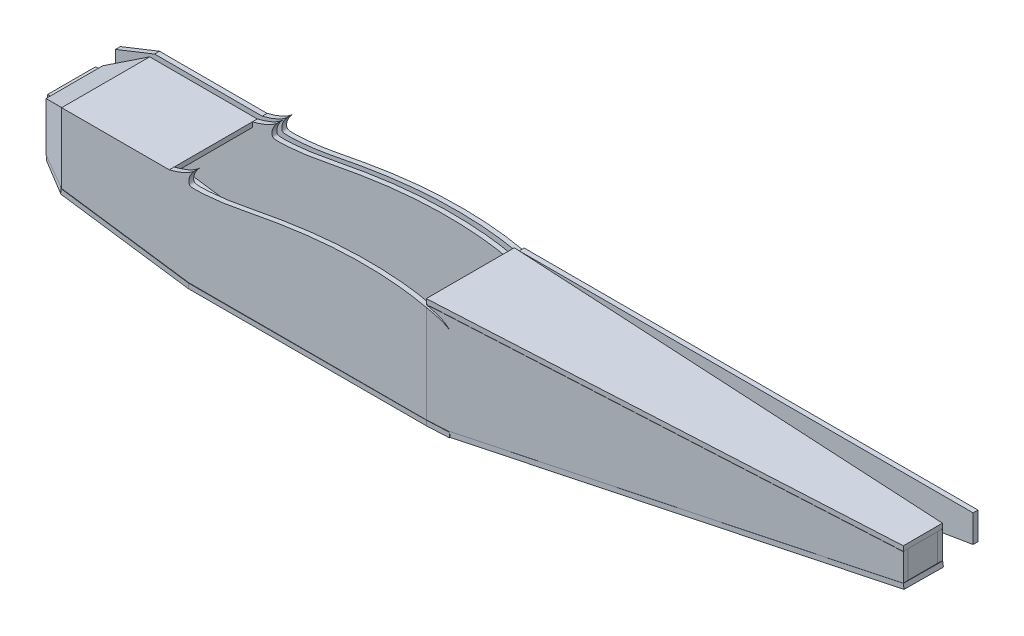
from build123d import *

# Parameters (mm, degrees)
BOSS_EXTRUDE1_DEPTH      = 5
BOSS_EXTRUDE5_DEPTH      = 5
BOSS_EXTRUDE7_DEPTH      = 5
BOSS_EXTRUDE8_DEPTH      = 0.002362017
BOSS_EXTRUDE8_DEPTH_BACK = 5
SKETCH29_W               = 49.059566024
SKETCH29_H               = 50
BOSS_EXTRUDE9_DEPTH      = 5
SKETCH30_W               = 30.063860272
SKETCH30_H               = 28.056676552
BOSS_EXTRUDE10_DEPTH     = 5
BOSS_EXTRUDE11_DEPTH     = 5
BOSS_EXTRUDE12_DEPTH     = 5
BOSS_EXTRUDE18_DEPTH     = 5
BOSS_EXTRUDE22_DEPTH     = 5
SKETCH38_W               = 131.749500249
SKETCH38_H               = 90.710541034
BOSS_EXTRUDE23_DEPTH     = 5
BOSS_EXTRUDE24_DEPTH     = 5
BOSS_EXTRUDE25_DEPTH     = 5
BOSS_EXTRUDE26_DEPTH     = 5


with BuildPart() as part:
    # Sketch2 → Boss-Extrude1 (new body)
    with BuildSketch(Plane.XY):
        with BuildLine():
            Line((706.745016675, 12.167167725), (242.745016675, 12.167167725))
            add(Edge.make_bspline(
                [(124.432769118, 12.787670712), (127.16227005, 13.092620358), (134.123597034, 13.82075776), (145.337160555, 14.772933919), (158.034195691, 15.535723016), (170.62317806, 15.955070434), (182.967539293, 16.008037018), (194.929558709, 15.691023935), (206.372264097, 15.011452524), (217.158058547, 13.978091085), (227.158530716, 12.630605082), (236.243477661, 11.008093479), (244.3063824, 9.1648962), (251.198649303, 7.192592998), (256.839258968, 5.087580751), (260.863688767, 3.161225049), (263.830793422, 1.380051863), (264.970627441, 0.690767223), (266.241142455, -0.171709465), (265.1271527, 0.658288782), (264.38761939, 1.383899074), (262.745556708, 2.899479064), (260.808306665, 4.511766368), (258.158315002, 6.13713136), (254.863030227, 7.712293785), (250.884845976, 9.356166566), (246.768501257, 10.850330318), (243.974418041, 11.774554958), (242.745016675, 12.167167725)],
                knots=[0.741308268, 0.741308268, 0.741308268, 0.741308268, 0.756094118, 0.778988554, 0.801889683, 0.824566598, 0.846792285, 0.868338291, 0.888978163, 0.908492011, 0.926658768, 0.943286193, 0.95816921, 0.971135822, 0.981955623, 0.990251791, 0.995852565, 0.999000406, 1, 1.000979678, 1.003648862, 1.007483499, 1.012095277, 1.017525591, 1.02405178, 1.031783051, 1.040677828, 1.047625399, 1.047625399, 1.047625399, 1.047625399], degree=3))
            add(Edge.make_bspline(
                [(-0.004631492, -0.177095853), (-3.2424e-05, -0.612159569), (0.085818354, -1.580724728), (0.522318686, -3.135725997), (2.379653438, -4.019341379), (4.8768644, -4.143309834), (8.293039686, -4.263460548), (12.589121207, -4.078204492), (17.716554755, -3.737760317), (23.618277347, -3.192442572), (30.233898006, -2.454604218), (37.531157228, -1.508412573), (45.506488949, -0.18596896), (54.198724376, 1.472353893), (63.651318834, 3.277138343), (73.818068814, 5.182731977), (84.635116432, 7.110039685), (96.023020904, 8.98673187), (107.893434076, 10.750140868), (117.420174926, 11.983062096), (122.977811963, 12.625117673), (124.432769118, 12.787670712)],
                knots=[0.511222834, 0.511222834, 0.511222834, 0.511222834, 0.513579311, 0.516446927, 0.519350053, 0.523823355, 0.529973794, 0.537715654, 0.546967844, 0.557637367, 0.569620481, 0.582804124, 0.597246961, 0.613135037, 0.6304436, 0.649056124, 0.668822257, 0.689594964, 0.711189651, 0.733426689, 0.741308268, 0.741308268, 0.741308268, 0.741308268], degree=3))
            add(Edge.make_bspline(
                [(-0.004631492, 0), (-0.005251256, -0.059005577), (-0.005255839, -0.118033803), (-0.004631492, -0.177095853)],
                knots=[0.510902931, 0.510902931, 0.510902931, 0.510902931, 0.511222834, 0.511222834, 0.511222834, 0.511222834], degree=3))
            add(Edge.make_bspline(
                [(6.12052156, 12.167167725), (5.616532595, 11.641520131), (4.39592468, 10.276576859), (2.737558538, 7.984495431), (1.299070701, 5.365975303), (0.37715223, 2.879814503), (0.032445951, 1.079184417), (-0.00297281, 0.157917482), (-0.004631492, 0)],
                knots=[0.485956775, 0.485956775, 0.485956775, 0.485956775, 0.489874508, 0.49580325, 0.501149412, 0.505903073, 0.510046769, 0.510902931, 0.510902931, 0.510902931, 0.510902931], degree=3))
            add(Edge.make_bspline(
                [(-20, 0), (-11.467631005, 2.199778438), (-0.826940934, 5.513158107), (6.12052156, 12.167167725)],
                knots=[0, 0, 0, 0, 0.753912396, 0.753912396, 0.753912396, 0.753912396], degree=3))
            Line((-20, 0), (-130, 0))
            Line((-130, 0), (-170, -15.889508827))
            Line((-170, -15.889508827), (-170, -65.889508827))
            Line((-170, -65.889508827), (-0.004631492, -90))
            Line((-0.004631492, -90), (265.995368508, -90))
            Line((265.995368508, -90), (706.745016675, -15.889508827))
            Line((706.745016675, -15.889508827), (706.745016675, 12.167167725))
        make_face()
    extrude(amount=BOSS_EXTRUDE1_DEPTH)


with BuildPart() as body_2:
    # Sketch12 → Boss-Extrude5 (new body)
    with BuildSketch(Plane(origin=(6.087960166, 0, 112.775462826), x_dir=(0, -1, 0), z_dir=(0.05390453463598798, 0, 0.998546093651003))):
        with BuildLine():
            Line((-12.167167725, 700.327022144), (-12.167167725, 237.00163469))
            add(Edge.make_bspline(
                [(-12.167167725, 237.00163469), (-11.774554958, 238.229248622), (-10.850330318, 241.019269503), (-9.356166566, 245.129629442), (-7.712293785, 249.102029786), (-6.13713136, 252.392523525), (-4.511766368, 255.038662348), (-2.899479064, 256.973095811), (-1.383899074, 258.612771088), (-0.658288782, 259.351229186), (0.171709465, 260.463599304), (-0.690767223, 259.1949315), (-1.380051863, 258.056754693), (-3.161225049, 255.09396393), (-5.087580751, 251.075385275), (-7.192592998, 245.442976529), (-8.583779515, 240.588505828), (-9.330125423, 237.630121112), (-9.484391278, 237.001634689)],
                knots=[0.485956775, 0.485956775, 0.485956775, 0.485956775, 0.492904346, 0.501799123, 0.509530394, 0.516056583, 0.521486897, 0.526098675, 0.529933312, 0.532602496, 0.533582174, 0.534581768, 0.537729608, 0.543330383, 0.551626551, 0.562446352, 0.575412963, 0.578902473, 0.578902473, 0.578902473, 0.578902473], degree=3))
            Line((-9.484391278, 237.001634689), (90, 237.00163469))
            Line((90, 237.00163469), (90, 260.218182689))
            Line((90, 260.218182689), (15.889508827, 700.327022144))
            Line((15.889508827, 700.327022144), (-12.167167725, 700.327022144))
        make_face()
    extrude(amount=-BOSS_EXTRUDE5_DEPTH)


with BuildPart() as body_3:
    # Sketch24 → Boss-Extrude7 (new body)
    with BuildSketch(Plane(origin=(-65.985541798, 0, 132.000175045), x_dir=(0, -1, 0), z_dir=(-0.44713474135516806, 0, 0.8944666137275594))):
        Polygon((0, -71.567185649), (71.562720135, -71.567185649), (65.889508827, -107.345850198), (15.889508827, -107.345850198), align=None)
    extrude(amount=-BOSS_EXTRUDE7_DEPTH)


with BuildPart() as body_4:
    # Sketch7 → Boss-Extrude8 (new, two sides)
    with BuildSketch(Plane.XY.offset(100)) as boss_extrude8_sk:
        with BuildLine():
            Line((242.745016675, 8.972673423), (242.745016675, 9.484391278))
            add(Edge.make_bspline(
                [(242.745016673, 9.484391278), (240.689974326, 9.988080671), (235.605317426, 11.122064688), (227.158530716, 12.630605082), (217.158058547, 13.978091085), (206.372264097, 15.011452524), (194.929558709, 15.691023935), (182.967539293, 16.008037018), (170.62317806, 15.955070434), (158.034195691, 15.535723016), (145.337160555, 14.772933919), (132.664724075, 13.696880632), (120.144057274, 12.335578494), (107.893434076, 10.750140868), (96.023020904, 8.98673187), (84.635116432, 7.110039685), (73.818068814, 5.182731977), (63.651318834, 3.277138343), (54.198724376, 1.472353893), (45.506488949, -0.18596896), (37.531157228, -1.508412573), (30.233898006, -2.454604218), (23.618277347, -3.192442572), (17.716554755, -3.737760317), (12.589121207, -4.078204492), (8.293039686, -4.263460548), (4.8768644, -4.143309834), (2.379653438, -4.019341379), (0.522318686, -3.135725997), (0.022653703, -1.355705166), (-0.062141966, 0.585088837), (0.37715223, 2.879814503), (1.299070701, 5.365975303), (2.737558538, 7.984495431), (4.395924665, 10.276576839), (5.616532561, 11.641520093), (6.120521508, 12.16716767)],
                knots=[0.578902473, 0.578902473, 0.578902473, 0.578902473, 0.590295981, 0.606923406, 0.625090162, 0.644604011, 0.665243883, 0.686789889, 0.709015576, 0.731692491, 0.75459362, 0.777488056, 0.800155485, 0.822392523, 0.84398721, 0.864759917, 0.88452605, 0.903138573, 0.920447137, 0.936335213, 0.950778049, 0.963961693, 0.975944807, 0.986614329, 0.995866519, 1.00360838, 1.009758819, 1.014232121, 1.017135247, 1.020002863, 1.023535405, 1.0276791, 1.032432762, 1.037778924, 1.043707666, 1.047625399, 1.047625399, 1.047625399, 1.047625399], degree=3))
            add(Edge.make_bspline(
                [(6.120521505, 12.167167672), (-0.82694099, 5.51315809), (-11.467631027, 2.199778432), (-20, 0)],
                knots=[0, 0, 0, 0, 0.753912394, 0.753912394, 0.753912394, 0.753912394], degree=3))
            Line((-20, 0), (-130, 0))
            Line((-130, 0), (-130, -71.562720135))
            Line((-130, -71.562720135), (-0.004631492, -90))
            Line((-0.004631492, -90), (242.745016675, -90))
            Line((242.745016675, -90), (242.745016675, 8.972673423))
        make_face()
    extrude(amount=BOSS_EXTRUDE8_DEPTH)
    extrude(boss_extrude8_sk.sketch, amount=-BOSS_EXTRUDE8_DEPTH_BACK)


with BuildPart() as body_5:
    # Mirror8: mirrored copy
    add(body_4.part.mirror(Plane.XY.offset(55)))


with BuildPart() as body_6:
    # Mirror8 2: mirrored copy
    add(body_2.part.mirror(Plane.XY.offset(55)))


with BuildPart() as body_7:
    # Mirror8 3: mirrored copy
    add(body_3.part.mirror(Plane.XY.offset(55)))


with BuildPart() as body_8:
    # Sketch29 → Boss-Extrude9 (new body)
    with BuildSketch(Plane.ZY.offset(159.767147216)):
        with Locations((55, -40.889508827)):
            Rectangle(SKETCH29_W, SKETCH29_H)
    extrude(amount=BOSS_EXTRUDE9_DEPTH)


with BuildPart() as body_9:
    # Sketch30 → Boss-Extrude10 (new body)
    with BuildSketch(Plane.ZY.offset(-705.127249733)):
        with Locations((55, -1.861170551)):
            Rectangle(SKETCH30_W, SKETCH30_H)
    extrude(amount=BOSS_EXTRUDE10_DEPTH)


with BuildPart() as body_3_1:
    add(body_3.part)

    add(body_4.part)  # Boss-Extrude11 merges body 4

    add(body_5.part)  # Boss-Extrude11 merges body 5

    add(body_7.part)  # Boss-Extrude11 merges body 7
    # Sketch31 → Boss-Extrude11 (add)
    with BuildSketch(Plane(origin=(-25.709288265, 51.780691105, 0), x_dir=(-0.895676417082623, -0.4447063704086497, 0), z_dir=(0.4447063704086497, -0.895676417082623, 0))):
        Polygon((116.437934221, -9.997637983), (116.437934221, -99.818556509), (152.168272, -84.002116081), (152.168272, -25.997883919), align=None)
    extrude(amount=BOSS_EXTRUDE11_DEPTH)

    # Sketch32 → Boss-Extrude12 (add)
    with BuildSketch(Plane(origin=(0, 0, 0), x_dir=(1, 0, 0), z_dir=(0, 1, 0))):
        Polygon((-20, -9.997637983), (-130, -9.997637983), (-130, -100), (-20, -100.002362017), align=None)
    extrude(amount=-BOSS_EXTRUDE12_DEPTH)


with BuildPart() as body_7_2:
    # Sketch35 → Boss-Extrude18 (new body)
    with BuildSketch(Plane(origin=(0, 12.367167725, 0), x_dir=(1, 0, 0), z_dir=(0, 1, 0))):
        Polygon((242.745016675, -100.002362017), (242.745016675, -9.997637983), (705.396772407, -34.975339396), (705.396772407, -75.024660604), align=None)
    extrude(amount=BOSS_EXTRUDE18_DEPTH)


with BuildPart() as body_2_1:
    add(body_2.part)

    # Sketch37 → Boss-Extrude22 (add)
    with BuildSketch(Plane(origin=(22.083717843, -131.336207808, 1.192145802), x_dir=(-0.9861573751236441, -0.16580520617812686, 0.0015050227484399235), z_dir=(0.16581203662353491, -0.9861167514496837, 0.00895103463732636))):
        Polygon((-693.08030813, -34.769382943), (-693.08030813, -75.077651477), (-246.535889921, -97.979995355), (-246.535889921, -10.414101442), align=None)
    extrude(amount=BOSS_EXTRUDE22_DEPTH)



with BuildPart() as body_8_2:
    # Sketch38 → Boss-Extrude23 (new body)
    with BuildSketch(Plane(origin=(-12.54680907, -88.463541289, 0), x_dir=(-0.9900913282108018, 0.14042493297762504, 0), z_dir=(-0.14042493297762504, -0.9900913282108018, 0))):
        with Locations((52.898651704, -54.903356729)):
            Rectangle(SKETCH38_W, SKETCH38_H)
    extrude(amount=BOSS_EXTRUDE23_DEPTH)

    # Sketch45 → Boss-Extrude25 (add)
    with BuildSketch(Plane(origin=(0, -90.24, 0), x_dir=(-1, 0, 0), z_dir=(0, -1, 0))):
        Polygon((0.401411214, -100.258627246), (0.401411214, -9.548086212), (-242.745016675, -9.997637983), (-242.745016675, -100.002362017), align=None)
    extrude(amount=BOSS_EXTRUDE25_DEPTH)


with BuildPart() as body_9_2:
    # Sketch44 → Boss-Extrude24 (new body)
    with BuildSketch(Plane(origin=(-16.260399931, -91.72559224, 0), x_dir=(-0.9846481744002387, 0.1745507738461144, 0), z_dir=(-0.1745507738461144, -0.9846481744002387, 0))):
        Polygon((115.748144024, -10.115773796), (147.506135541, -25.860574924), (147.506135541, -83.361404055), (116.180199117, -99.791548904), align=None)
    extrude(amount=BOSS_EXTRUDE24_DEPTH)


with BuildPart() as body_2_2:
    add(body_2_1.part)

    add(body_8_2.part)  # Boss-Extrude26 merges body 8 2
    # Sketch47 → Boss-Extrude26 (add)
    with BuildSketch(Plane(origin=(0, -90.24, 0), x_dir=(-1, 0, 0), z_dir=(0, -1, 0))):
        Polygon((-242.745016675, -100.002362017), (-265.268617939, -98.899911982), (-265.268617939, -11.456874844), (-242.745016675, -9.997637983), align=None)
    extrude(amount=BOSS_EXTRUDE26_DEPTH)


solid = Compound([part.part, body_6.part, body_8.part, body_9.part, body_3_1.part, body_7_2.part, body_9_2.part, body_2_2.part])
